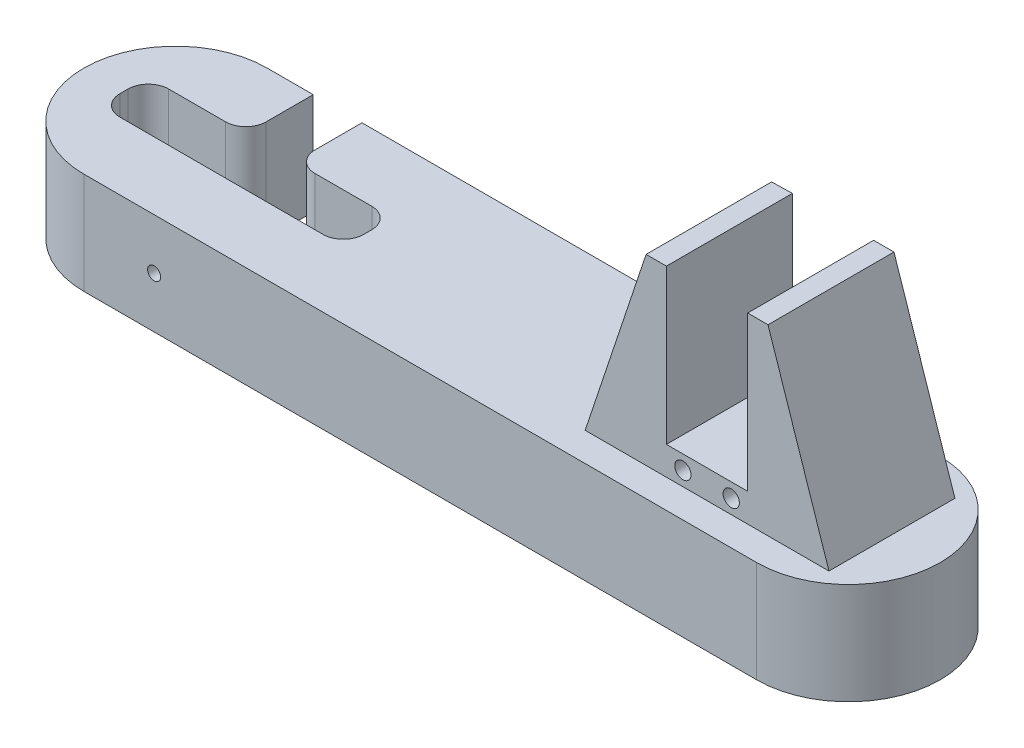
from build123d import *

# Parameters (mm, degrees)
SKETCH_1_R                = 1.985
EXTRUDE_1_DEPTH           = 12
CUT_EXTRUDE_1_DEPTH       = 21
CUT_EXTRUDE_6_DEPTH       = 21
SKETCH_12_R               = 1.985
EXTRUDE_11_DEPTH          = 5
SKETCH_13_R               = 1.985
EXTRUDE_12_DEPTH          = 5
SKETCH_14_W               = 2.04
SKETCH_14_H               = 20
CUT_EXTRUDE_7_DEPTH       = 21
SKETCH_15_W               = 6
SKETCH_15_H               = 6
EXTRUDE_13_DEPTH          = 100
EXTRUDE_14_DEPTH          = 25
EXTRUDE_19_DEPTH          = 7
SKETCH_31_W               = 5
SKETCH_31_H               = 31
EXTRUDE_20_DEPTH          = 45
EXTRUDE_21_DEPTH          = 31
CUT_EXTRUDE_16_DEPTH      = 60
SKETCH_38_W               = 0.2
SKETCH_38_H               = 20
CUT_EXTRUDE_18_DEPTH      = 187
FILLET_2_R                = 10
EXTRUDE_22_DEPTH          = 12
EXTRUDE_23_DEPTH          = 12
SKETCH_46_W               = 12
SKETCH_46_H               = 6
EXTRUDE_24_DEPTH          = 72
SKETCH_45_W               = 12
SKETCH_45_H               = 12
EXTRUDE_26_DEPTH          = 34.5
CUT_EXTRUDE_22_DEPTH      = 56
CUT_EXTRUDE_22_DEPTH_BACK = 183
SKETCH_52_W               = 276.860759989
SKETCH_52_H               = 117.184268482
CUT_EXTRUDE_24_DEPTH      = 26
SKETCH_56_R               = 1.7
CUT_EXTRUDE_26_DEPTH      = 17.579802914
CUT_EXTRUDE_26_DEPTH_BACK = 64.5
EXTRUDE_27_DEPTH          = 12
CUT_EXTRUDE_27_DEPTH      = 12
SKETCH_59_W               = 12
SKETCH_59_H               = 29.920197086
EXTRUDE_29_DEPTH          = 25
SKETCH_60_W               = 24
SKETCH_60_H               = 12
EXTRUDE_30_DEPTH          = 12
EXTRUDE_30_DEPTH_BACK     = 25
CUT_EXTRUDE_29_DEPTH      = 141.276417548
CUT_EXTRUDE_29_DEPTH_BACK = 26
SKETCH_64_R               = 3.1
CUT_EXTRUDE_30_DEPTH      = 3
SKETCH_65_R               = 1.6
CUT_EXTRUDE_32_DEPTH      = 14.579802914
FILLET_3_R                = 5
FILLET_4_R                = 5


with BuildPart() as part:
    # 草圖1 → 填料-伸長1 (new body)
    with BuildSketch(Plane.XY):
        with BuildLine():
            Line((-10, 0), (-10, -30.276417548))
            Line((-10, -30.276417548), (10, -30.276417548))
            Line((10, -30.276417548), (10, 0))
            ThreePointArc((10, 0), (0, 10), (-10, 0))
        make_face()
        Circle(SKETCH_1_R, mode=Mode.SUBTRACT)
    extrude(amount=EXTRUDE_1_DEPTH)

    # 草圖2 → 除料-伸長1 (cut, through all)
    with BuildSketch(Plane(origin=(10, 0, 0), x_dir=(0, 0, -1), z_dir=(1, 0, 0))):
        Polygon((-9, 0), (-6, 0), (-3, 0), (-3, 15.780779257), (-9, 15.780779257), align=None)
        Polygon((-3, 0), (-6, 0), (-9, 0), (-8.60053373, -20), (-3, -20), align=None)
    extrude(amount=-CUT_EXTRUDE_1_DEPTH, mode=Mode.SUBTRACT)

    # 草圖11 → 除料-伸長6 (cut, through all)
    with BuildSketch(Plane(origin=(10, 0, 0), x_dir=(0, 0, -1), z_dir=(1, 0, 0))):
        Polygon((-9, 0), (-9, -20), (-8.60053373, -20), align=None)
    extrude(amount=-CUT_EXTRUDE_6_DEPTH, mode=Mode.SUBTRACT)

    # 草圖12 → 填料-伸長11 (add)
    with BuildSketch(Plane.XY.offset(12)):
        with BuildLine():
            ThreePointArc((10, 0), (0, 10), (-10, 0))
            ThreePointArc((-10, 0), (0, -10), (10, 0))
        make_face()
        Circle(SKETCH_12_R, mode=Mode.SUBTRACT)
        with BuildLine():
            ThreePointArc((10, 0), (0, -10), (-10, 0))
            Line((-10, 0), (-10, -30.276417548))
            Line((-10, -30.276417548), (10, -30.276417548))
            Line((10, -30.276417548), (10, 0))
        make_face()
    extrude(amount=EXTRUDE_11_DEPTH)

    # 草圖13 → 填料-伸長12 (add)
    with BuildSketch(Plane(origin=(0, 0, 0), x_dir=(-1, 0, 0), z_dir=(0, 0, -1))):
        with BuildLine():
            ThreePointArc((10, 0), (0, 10), (-10, 0))
            ThreePointArc((-10, 0), (0, -10), (10, 0))
        make_face()
        Circle(SKETCH_13_R, mode=Mode.SUBTRACT)
        with BuildLine():
            ThreePointArc((10, 0), (0, -10), (-10, 0))
            Line((-10, 0), (-10, -30.276417548))
            Line((-10, -30.276417548), (10, -30.276417548))
            Line((10, -30.276417548), (10, 0))
        make_face()
    extrude(amount=EXTRUDE_12_DEPTH)

    # 草圖14 → 除料-伸長7 (cut, through all)
    with BuildSketch(Plane.ZY.offset(10)):
        Polygon((3, 0), (3, -20), (9, -20), (9, 0), (11.04, 0), (11.04, 10), (3, 10), (0.96, 10), (0.96, 0), align=None)
        with Locations((1.98, -10)):
            Rectangle(SKETCH_14_W, SKETCH_14_H)
        with Locations((10.02, -10)):
            Rectangle(SKETCH_14_W, SKETCH_14_H)
    extrude(amount=-CUT_EXTRUDE_7_DEPTH, mode=Mode.SUBTRACT)

    # 草圖15 → 填料-伸長13 (add)
    with BuildSketch(Plane.XZ.offset(30.276417548)):
        with Locations((3, 9)):
            Rectangle(SKETCH_15_W, SKETCH_15_H)
        with Locations((-3, 9)):
            Rectangle(SKETCH_15_W, SKETCH_15_H)
        with Locations((3, 3)):
            Rectangle(SKETCH_15_W, SKETCH_15_H)
        with Locations((-3, 3)):
            Rectangle(SKETCH_15_W, SKETCH_15_H)
    extrude(amount=EXTRUDE_13_DEPTH)

    # 草圖16 → 填料-伸長14 (add)
    with BuildSketch(Plane.XZ.offset(130.276417548)):
        Polygon((176, -54), (176, 6), (176, 96), (-61, 96), (-61, 6), (-61, -54), align=None)
    extrude(amount=EXTRUDE_14_DEPTH)

    # 草圖30 → 填料-伸長19 (add)
    with BuildSketch(Plane(origin=(0, -130.276417548, 0), x_dir=(1, 0, 0), z_dir=(0, 1, 0))):
        Polygon((119, -68), (139, -68), (139, -37), (129, -37), (119, -37), align=None)
    extrude(amount=EXTRUDE_19_DEPTH)

    # 草圖31 → 填料-伸長20 (add)
    with BuildSketch(Plane(origin=(0, -130.276417548, 0), x_dir=(1, 0, 0), z_dir=(0, 1, 0))):
        Polygon((119, -68), (114, -68), (114, -37.129725066), (119, -37), align=None)
        with Locations((141.5, -52.5)):
            Rectangle(SKETCH_31_W, SKETCH_31_H)
    extrude(amount=EXTRUDE_20_DEPTH)

    # 草圖33 → 填料-伸長21 (add)
    with BuildSketch(Plane.XY.offset(68)):
        Polygon((159, -130.276417548), (144, -130.276417548), (144, -85.276417548), align=None)
        Polygon((114, -85.276417548), (99, -130.276417548), (114, -130.276417548), align=None)
    extrude(amount=-EXTRUDE_21_DEPTH)

    # 草圖35 → 除料-伸長16 (cut, through all)
    with BuildSketch(Plane(origin=(0, 0, 37), x_dir=(-1, 0, 0), z_dir=(0, 0, -1))):
        with BuildLine():
            ThreePointArc((-132.95, -126.776417548), (-134.95, -124.776417548), (-136.95, -126.776417548))
            Line((-136.95, -126.776417548), (-132.95, -126.776417548))
        make_face()
        with BuildLine():
            Line((-132.95, -126.776417548), (-136.95, -126.776417548))
            ThreePointArc((-136.95, -126.776417548), (-134.95, -128.776417548), (-132.95, -126.776417548))
        make_face()
        with BuildLine():
            ThreePointArc((-121.05, -126.776417548), (-123.05, -124.776417548), (-125.05, -126.776417548))
            Line((-125.05, -126.776417548), (-121.05, -126.776417548))
        make_face()
        with BuildLine():
            Line((-121.05, -126.776417548), (-125.05, -126.776417548))
            ThreePointArc((-125.05, -126.776417548), (-123.05, -128.776417548), (-121.05, -126.776417548))
        make_face()
    extrude(amount=-CUT_EXTRUDE_16_DEPTH, mode=Mode.SUBTRACT)

    # 草圖38 → 除料-伸長18 (cut, through all)
    with BuildSketch(Plane.ZY.offset(10)):
        Polygon((11.04, 10), (0.96, 10), (0.76, 10), (0.76, 0), (0.96, 0), (0.96, -20), (11.04, -20), (11.04, 0), (11.24, 0), (11.24, 10), align=None)
        with Locations((0.86, -10)):
            Rectangle(SKETCH_38_W, SKETCH_38_H)
        with Locations((11.14, -10)):
            Rectangle(SKETCH_38_W, SKETCH_38_H)
    extrude(amount=-CUT_EXTRUDE_18_DEPTH, mode=Mode.SUBTRACT)

    # 圓角2
    fillet_2_edges = [part.edges().sort_by_distance(p)[0] for p in [
        (-61, -142.776417548, 96),
        (-61, -142.776417548, -54),
        (176, -142.776417548, -54),
        (176, -142.776417548, 96),
    ]]
    fillet(fillet_2_edges, radius=FILLET_2_R)

    # 草圖39 → 填料-伸長22 (add)
    with BuildSketch(Plane(origin=(0, 0, 0), x_dir=(-1, 0, 0), z_dir=(0, 0, -1))):
        Polygon((-6, -80.276417548), (-16, -130.276417548), (-6, -130.276417548), align=None)
        Polygon((6, -80.276417548), (16, -130.276417548), (6, -130.276417548), align=None)
    extrude(amount=-EXTRUDE_22_DEPTH)

    # 草圖40 → 填料-伸長23 (add)
    with BuildSketch(Plane(origin=(6, 0, 0), x_dir=(0, 0, -1), z_dir=(1, 0, 0))):
        Polygon((-12, -80.276417548), (-22, -130.276417548), (-12, -130.276417548), align=None)
        Polygon((0, -80.276417548), (11.303196885, -130.276417548), (0, -130.276417548), align=None)
    extrude(amount=-EXTRUDE_23_DEPTH)

    # 草圖46 → 填料-伸長24 (add)
    with BuildSketch(Plane(origin=(0, -130.276417548, 0), x_dir=(1, 0, 0), z_dir=(0, 1, 0))):
        with Locations((0, -55.5)):
            Rectangle(SKETCH_46_W, SKETCH_46_H)
        with Locations((0, -49.5)):
            Rectangle(SKETCH_46_W, SKETCH_46_H)
    extrude(amount=EXTRUDE_24_DEPTH)

    # 草圖45 → 填料-伸長26 (add)
    with BuildSketch(Plane.XY.offset(12)):
        with Locations((0, -64.276417548)):
            Rectangle(SKETCH_45_W, SKETCH_45_H)
    extrude(amount=EXTRUDE_26_DEPTH)

    # 草圖50 → 除料-伸長22 (cut, two sides)
    with BuildSketch(Plane.ZY.offset(6)) as cut_extrude_22_sk:
        Polygon((12, -70.276417548), (0, -70.276417548), (-67.39172142, -119.054967007), (-58.508131327, -164.361276479), (22, -164.361276479), (22, -130.276417548), (21.222089752, -86.407773417), align=None)
    extrude(amount=CUT_EXTRUDE_22_DEPTH, mode=Mode.SUBTRACT)
    extrude(cut_extrude_22_sk.sketch, amount=-CUT_EXTRUDE_22_DEPTH_BACK, mode=Mode.SUBTRACT)

    # 草圖52 → 除料-伸長24 (cut, through all)
    with BuildSketch(Plane(origin=(0, -130.276417548, 0), x_dir=(1, 0, 0), z_dir=(0, 1, 0))):
        with Locations((58.121400767, -52.5)):
            Rectangle(SKETCH_52_W, SKETCH_52_H)
        with BuildLine():
            Line((-17.31105843, -29.920197086), (148.30684395, -29.920197086))
            ThreePointArc((148.30684395, -29.920197086), (170.886646864, -52.5), (148.30684395, -75.079802914))
            Line((148.30684395, -75.079802914), (-17.31105843, -75.079802914))
            ThreePointArc((-17.31105843, -75.079802914), (-39.890861345, -52.5), (-17.31105843, -29.920197086))
        make_face(mode=Mode.SUBTRACT)
    extrude(amount=-CUT_EXTRUDE_24_DEPTH, mode=Mode.SUBTRACT)

    # 草圖56 → 除料-伸長26 (cut, two sides)
    with BuildSketch(Plane.XY.offset(58.5)) as cut_extrude_26_sk:
        with Locations((0, -64.276417548)):
            Circle(SKETCH_56_R)
    extrude(amount=CUT_EXTRUDE_26_DEPTH, mode=Mode.SUBTRACT)
    extrude(cut_extrude_26_sk.sketch, amount=-CUT_EXTRUDE_26_DEPTH_BACK, mode=Mode.SUBTRACT)

    # 草圖57 → 填料-伸長27 (add)
    with BuildSketch(Plane.ZY.offset(6)):
        Polygon((12, -70.276417548), (0, -70.276417548), (0, -130.276417548), (46.5, -130.276417548), (46.5, -118.276417548), (45.651807849, -118.276417548), (12, -118.276417548), align=None)
    extrude(amount=-EXTRUDE_27_DEPTH)

    # 草圖58 → 除料-伸長27 (cut)
    with BuildSketch(Plane.ZY.offset(6)):
        Polygon((12, -50.353469845), (12, -118.276417548), (97.717444729, -118.276417548), (103.225359423, -26.791834768), align=None)
    extrude(amount=-CUT_EXTRUDE_27_DEPTH, mode=Mode.SUBTRACT)

    # 草圖59 → 填料-伸長29 (add)
    with BuildSketch(Plane.XZ.offset(130.276417548)):
        with Locations((0, 14.960098543)):
            Rectangle(SKETCH_59_W, SKETCH_59_H)
    extrude(amount=EXTRUDE_29_DEPTH)

    # 草圖60 → 填料-伸長30 (add, two sides)
    with BuildSketch(Plane(origin=(0, -130.276417548, 0), x_dir=(1, 0, 0), z_dir=(0, 1, 0))) as extrude_30_sk:
        with Locations((18, -52.5)):
            Rectangle(SKETCH_60_W, SKETCH_60_H)
        with Locations((-18, -52.5)):
            Rectangle(SKETCH_60_W, SKETCH_60_H)
    extrude(amount=EXTRUDE_30_DEPTH)
    extrude(extrude_30_sk.sketch, amount=-EXTRUDE_30_DEPTH_BACK)

    # 草圖61 → 除料-伸長29 (cut, two sides)
    with BuildSketch(Plane(origin=(0, -130.276417548, 0), x_dir=(1, 0, 0), z_dir=(0, 1, 0))) as cut_extrude_29_sk:
        Polygon((-6, -46.5), (-30, -46.5), (-30, -58.5), (30, -58.5), (30, -46.5), (6, -46.5), (6, -25.627647678), (24.570908719, -19.281918297), (2.903681873, 31.931526974), (-27.080258307, 24.052535394), (-16.735277834, -15.315862515), (-15.070735332, -21.650371482), (-6, -26.781810366), align=None)
    extrude(amount=CUT_EXTRUDE_29_DEPTH, mode=Mode.SUBTRACT)
    extrude(cut_extrude_29_sk.sketch, amount=-CUT_EXTRUDE_29_DEPTH_BACK, mode=Mode.SUBTRACT)

    # 草圖64 → 除料-伸長30 (cut)
    with BuildSketch(Plane(origin=(0, 0, 58.5), x_dir=(-1, 0, 0), z_dir=(0, 0, -1))):
        with Locations((0, -142.776417548)):
            Circle(SKETCH_64_R)
    extrude(amount=-CUT_EXTRUDE_30_DEPTH, mode=Mode.SUBTRACT)

    # 草圖65 → 除料-伸長32 (cut, through all)
    with BuildSketch(Plane(origin=(0, 0, 61.5), x_dir=(-1, 0, 0), z_dir=(0, 0, -1))):
        with Locations((0, -142.776417548)):
            Circle(SKETCH_65_R)
    extrude(amount=-CUT_EXTRUDE_32_DEPTH, mode=Mode.SUBTRACT)

    # 圓角3
    fillet_3_edges = [part.edges().sort_by_distance(p)[0] for p in [
        (30, -142.776417548, 58.5),
    ]]
    fillet(fillet_3_edges, radius=FILLET_3_R)

    # 圓角4
    fillet_4_edges = [part.edges().sort_by_distance(p)[0] for p in [
        (30, -142.776417548, 46.5),
        (6, -142.776417548, 46.5),
        (-30, -142.776417548, 46.5),
        (-30, -142.776417548, 58.5),
        (-6, -142.776417548, 46.5),
    ]]
    fillet(fillet_4_edges, radius=FILLET_4_R)


solid = part.part
